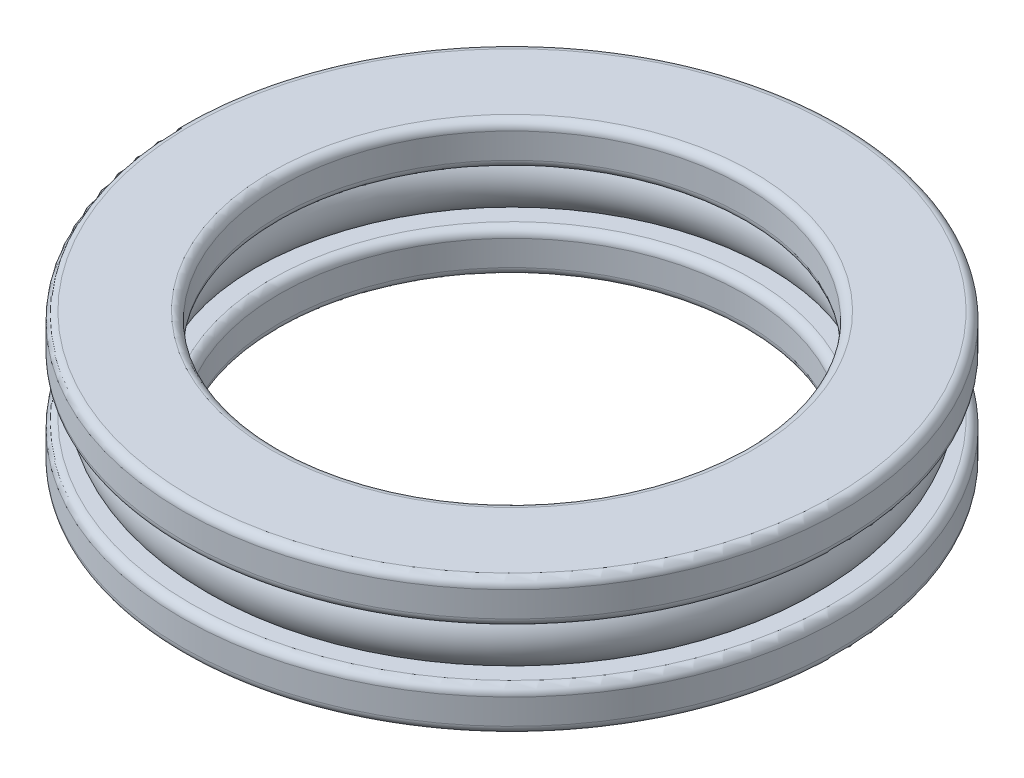
from build123d import *

# Parameters (mm, degrees)
FILLET1_R = 1


with BuildPart() as part:
    # Sketch1 → Revolve1 (revolve)
    with BuildSketch(Plane.XY):
        with BuildLine():
            Line((27.5, -3), (30.604248689, -3))
            ThreePointArc((30.604248689, -3), (29.25, 0), (30.604248689, 3))
            Line((30.604248689, 3), (27.5, 3))
            Line((27.5, 3), (27.5, 8))
            Line((27.5, 8), (39, 8))
            Line((39, 8), (39, 3))
            Line((39, 3), (35.895751311, 3))
            ThreePointArc((35.895751311, 3), (37.25, 0), (35.895751311, -3))
            Line((35.895751311, -3), (39, -3))
            Line((39, -3), (39, -8))
            Line((39, -8), (27.5, -8))
            Line((27.5, -8), (27.5, -3))
        make_face()
    revolve(axis=Axis((0, 0, 0), (0, 1, 0)))

    # Fillet1
    fillet1_edges = [part.edges().sort_by_distance(p)[0] for p in [
        (-27.5, -3, 0),
        (-27.5, 3, 0),
        (-27.5, 8, 0),
        (-39, 8, 0),
        (-39, 3, 0),
        (-39, -3, 0),
        (-39, -8, 0),
        (-27.5, -8, 0),
    ]]
    fillet(fillet1_edges, radius=FILLET1_R)


solid = part.part
